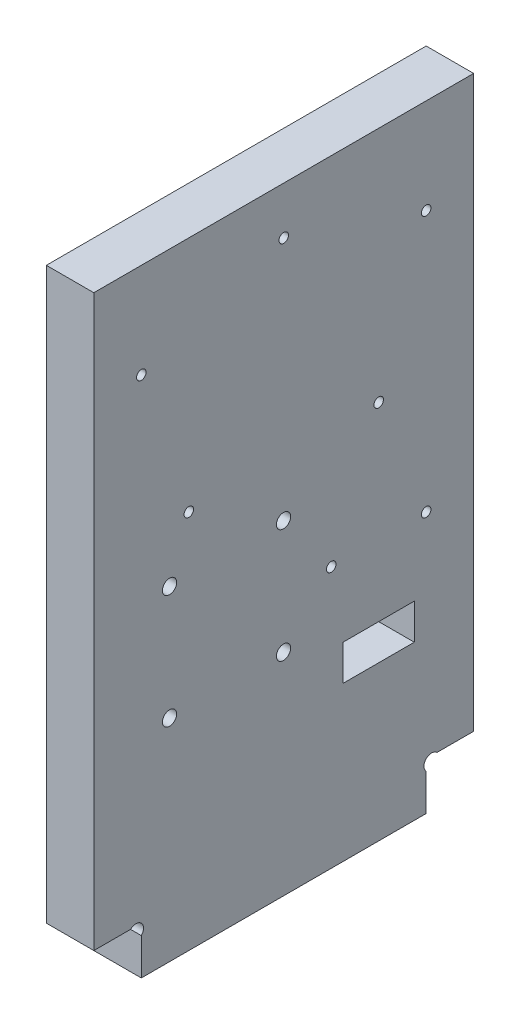
from build123d import *

# Parameters (mm, degrees)
EXTRUSION1_DEPTH        = 10
ESQUISSE2_R             = 1
ESQUISSE2_R_2           = 1.5
ENL_V_MAT_EXTRU_1_DEPTH = 11
ESQUISSE3_W             = 15
ESQUISSE3_H             = 7.5
ENL_V_MAT_EXTRU_2_DEPTH = 11


with BuildPart() as part:
    # Esquisse1 → Extrusion1 (new body)
    with BuildSketch(Plane(origin=(0, 0, 0), x_dir=(0, 0, -1), z_dir=(1, 0, 0))):
        with BuildLine():
            Line((10, 7.7372583), (10, 0))
            Line((10, 0), (70, 0))
            Line((70, 0), (70, 7.7372583))
            ThreePointArc((70, 7.7372583), (70, 10), (72.2627417, 10))
            Line((72.2627417, 10), (80, 10))
            Line((80, 10), (80, 130))
            Line((80, 130), (0, 130))
            Line((0, 130), (0, 10))
            Line((0, 10), (7.7372583, 10))
            ThreePointArc((7.7372583, 10), (10, 10), (10, 7.7372583))
        make_face()
    extrude(amount=EXTRUSION1_DEPTH)

    # Esquisse2 → Enlèv. mat.-Extru.1 (cut, through all)
    with BuildSketch(Plane(origin=(10, 0, 0), x_dir=(0, 0, -1), z_dir=(1, 0, 0))):
        with Locations((60, 80)):
            Circle(ESQUISSE2_R)
        with Locations((10, 110)):
            Circle(ESQUISSE2_R)
        with Locations(Location((20, 80, 0), (0, 0, 180))):  # turned: the seam where the file's is
            Circle(ESQUISSE2_R)
        with Locations((70, 110)):
            Circle(ESQUISSE2_R)
        with Locations((15.95, 68.45)):
            Circle(ESQUISSE2_R_2)
        with Locations((15.95, 44.45)):
            Circle(ESQUISSE2_R_2)
        with Locations((39.95, 44.45)):
            Circle(ESQUISSE2_R_2)
        with Locations((39.95, 68.45)):
            Circle(ESQUISSE2_R_2)
        with Locations((40, 120)):
            Circle(ESQUISSE2_R)
        with Locations((70, 55)):
            Circle(ESQUISSE2_R)
        with Locations((50, 55)):
            Circle(ESQUISSE2_R)
    extrude(amount=-ENL_V_MAT_EXTRU_1_DEPTH, mode=Mode.SUBTRACT)

    # Esquisse3 → Enlèv. mat.-Extru.2 (cut, through all)
    with BuildSketch(Plane.ZY):
        with Locations((-60, 36.25)):
            Rectangle(ESQUISSE3_W, ESQUISSE3_H)
    extrude(amount=-ENL_V_MAT_EXTRU_2_DEPTH, mode=Mode.SUBTRACT)


solid = part.part
